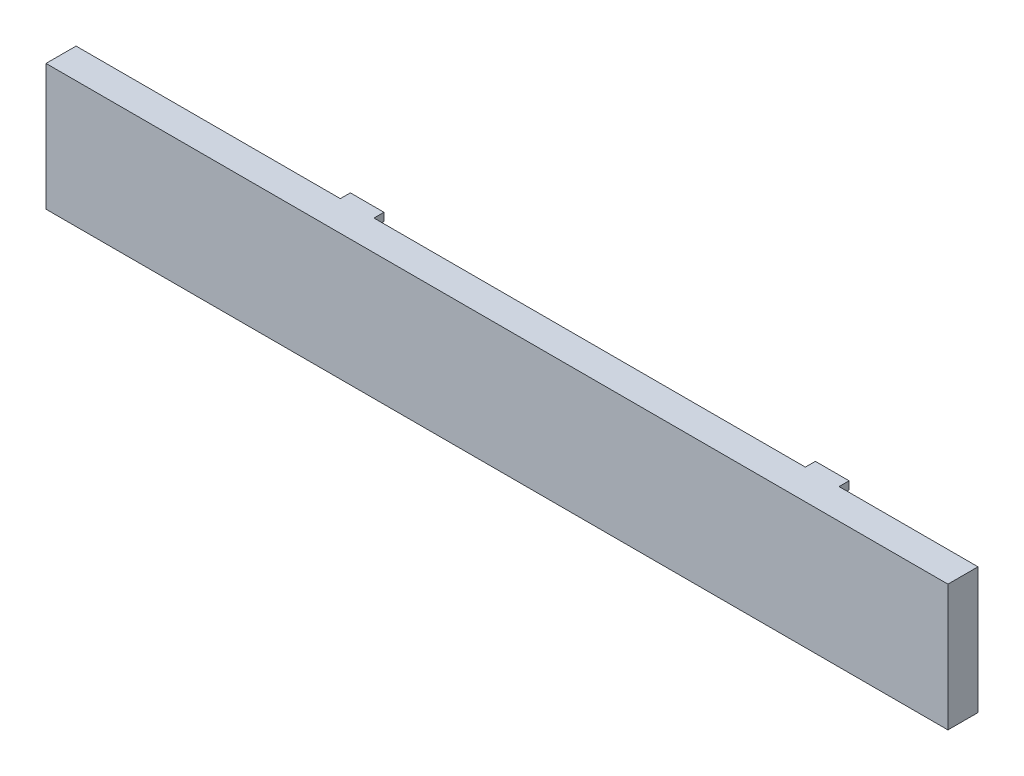
from build123d import *

# Parameters (mm, degrees)
SKETCH_1_W          = 450
SKETCH_1_H          = 63
EXTRUDE_1_DEPTH     = 20
CUT_EXTRUDE_START   = -20
SKETCH_2_W          = 445
SKETCH_2_H          = 55
CUT_EXTRUDE_1_DEPTH = 10
SKETCH_3_W          = 131.848612651
SKETCH_3_H          = 5
SKETCH_3_W_2        = 215.237788284
SKETCH_3_W_3        = 69.324505159
CUT_EXTRUDE_2_DEPTH = 64


with BuildPart() as part:
    # 草图1 → 凸台-拉伸1 (new body)
    with BuildSketch(Plane.XY):
        with Locations((-1046.220159151, 824.932360743)):
            Rectangle(SKETCH_1_W, SKETCH_1_H)
    extrude(amount=EXTRUDE_1_DEPTH)

    # 草图2 → 切除-拉伸1 (cut)
    with BuildSketch(Plane.XY.offset(20).offset(CUT_EXTRUDE_START)):
        with Locations((-1048.720159151, 824.932360743)):
            Rectangle(SKETCH_2_W, SKETCH_2_H)
    extrude(amount=CUT_EXTRUDE_1_DEPTH, mode=Mode.SUBTRACT)

    # 草图3 → 切除-拉伸2 (cut, through all)
    with BuildSketch(Plane.XZ.offset(-793.432360743)):
        with Locations((-1205.295852826, 2.5)):
            Rectangle(SKETCH_3_W, SKETCH_3_H)
        with Locations((-1014.979168507, 2.5)):
            Rectangle(SKETCH_3_W_2, SKETCH_3_H)
        with Locations((-855.882411731, 2.5)):
            Rectangle(SKETCH_3_W_3, SKETCH_3_H)
    extrude(amount=-CUT_EXTRUDE_2_DEPTH, mode=Mode.SUBTRACT)


solid = part.part
